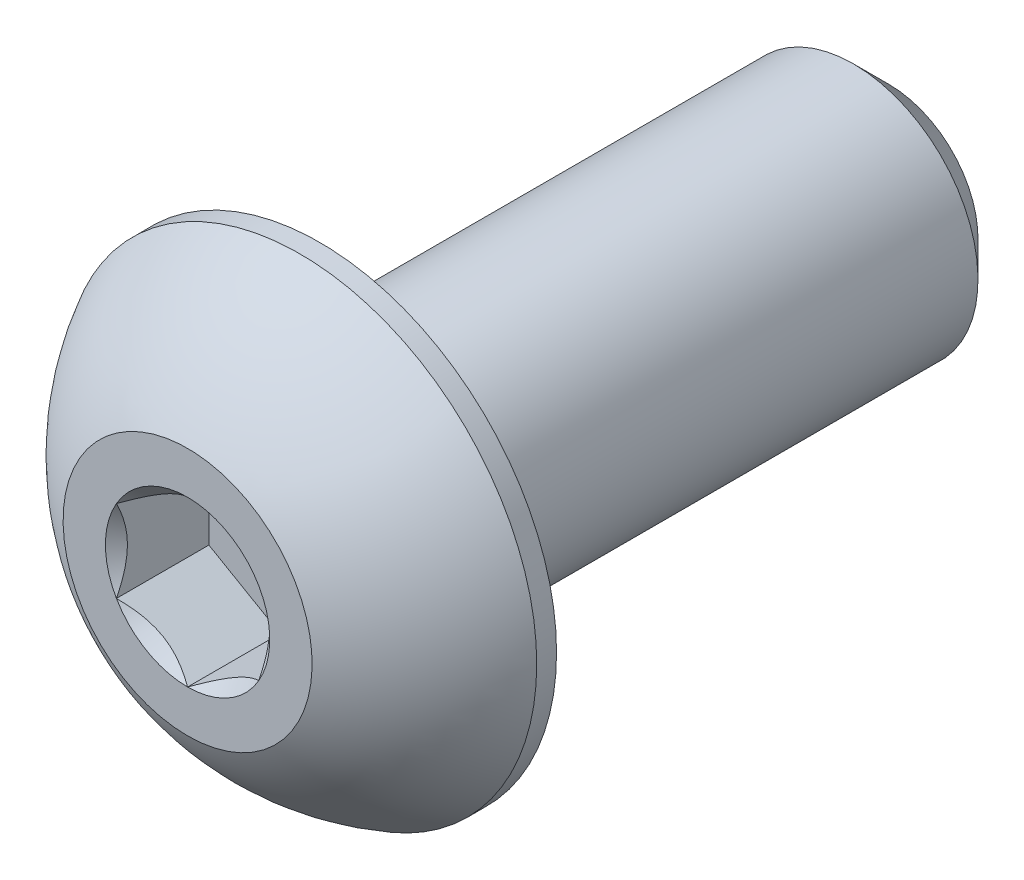
from build123d import *

# Parameters (mm, degrees)
SKETCH1_W          = 9.525
SKETCH1_H          = 2.0828
CHAMFER1_SIZE      = 0.5953125
CUT_EXTRUDE2_DEPTH = 1.54686


with BuildPart() as part:
    # Sketch1 → Revolve1 (revolve)
    with BuildSketch(Plane(origin=(0, 0, 0), x_dir=(0, 0, -1), z_dir=(1, 0, 0))):
        with Locations((6.9723, 1.0414)):
            Rectangle(SKETCH1_W, SKETCH1_H)
    revolve(axis=Axis((0, 0, -11.7348), (0, 0, 1)))

    # Chamfer1
    chamfer1_edges = [part.edges().sort_by_distance(p)[0] for p in [
        (0, -2.0828, -11.7348),
    ]]
    chamfer(chamfer1_edges, length=CHAMFER1_SIZE)

    # Sketch7 → Revolve2 (revolve)
    with BuildSketch(Plane(origin=(0, 0, 0), x_dir=(0, 0, -1), z_dir=(1, 0, 0)), mode=Mode.PRIVATE) as revolve2_sk:
        with BuildLine():
            Line((1.87833, 3.9624), (2.2098, 3.9624))
            Line((2.2098, 3.9624), (2.2098, 0))
            Line((2.2098, 0), (0, 0))
            Line((0, 0), (0, 2.0828))
            ThreePointArc((0, 2.0828), (0.796523813, 3.165144808), (1.87833, 3.9624))
        make_face()
    revolve(revolve2_sk.sketch.rotate(Axis((0, 0, 0), (0, 0, -1)), 180), axis=Axis((0, 0, 0), (0, 0, -1)))

    # Sketch5 → Cut-Extrude2 (cut)
    with BuildSketch(Plane.XY):
        Polygon((1.190625, -0.687407664), (1.190625, 0.687407664), (0, 1.374815329), (-1.190625, 0.687407664), (-1.190625, -0.687407664), (0, -1.374815329), align=None)
    extrude(amount=-CUT_EXTRUDE2_DEPTH, mode=Mode.SUBTRACT)

    # Cut-Extrude3 cone 1 section (through the dimple's axis) → Cut-Extrude3 (revolve, cut)
    with BuildSketch(Plane(origin=(0, 0, 0), x_dir=(0, -1, 0), z_dir=(1, 0, 0))):
        Polygon((0, 0), (1.374815329, 0), (0, 1.374815329), align=None)
    revolve(axis=Axis((0, 0, 0), (0, 0, -1)), mode=Mode.SUBTRACT)


solid = part.part
